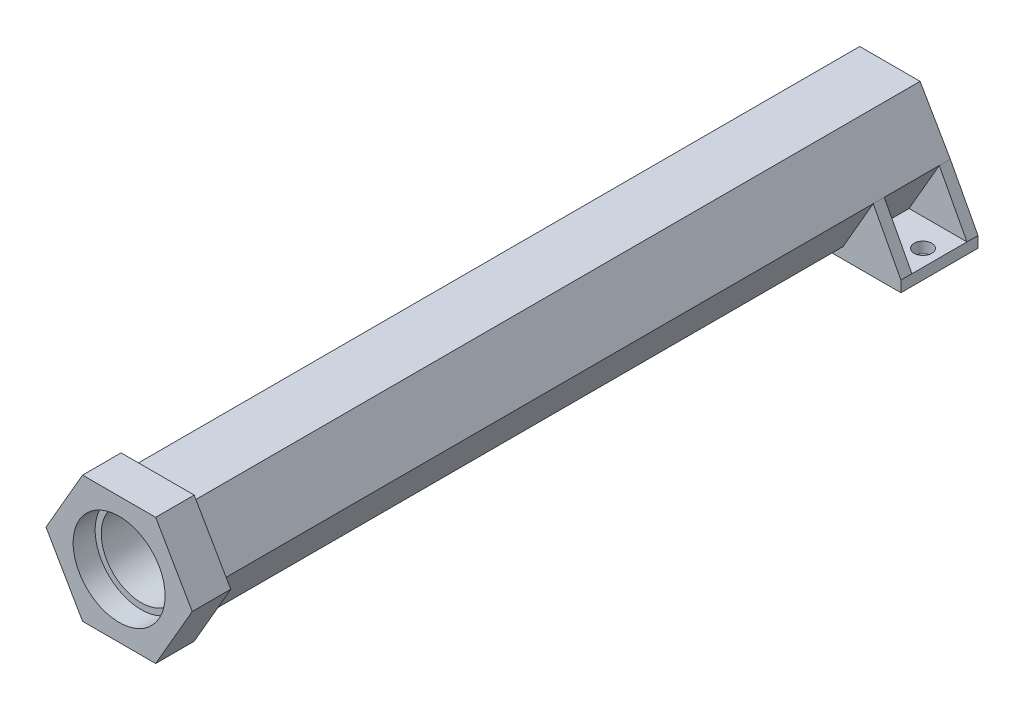
from build123d import *

# Parameters (mm, degrees)
SKIZZE1_R                        = 7.25
AUFSATZ_LINEAR_AUSTRAGEN1_DEPTH  = 136
SKIZZE2_R                        = 7.25
AUFSATZ_LINEAR_AUSTRAGEN2_DEPTH  = 2
SKIZZE3_R                        = 8.35
AUFSATZ_LINEAR_AUSTRAGEN3_DEPTH  = 7
AUFSATZ_LINEAR_AUSTRAGEN6_DEPTH  = 2
LINEARES_MUSTER3_COUNT           = 2
LINEARES_MUSTER3_PITCH           = 12
SKIZZE12_W                       = 32
SKIZZE12_H                       = 14
SKIZZE12_R                       = 1.6
AUFSATZ_LINEAR_AUSTRAGEN14_DEPTH = 2
SKIZZE14_R                       = 2.6
SCHNITT_LINEAR_AUSTRAGEN1_DEPTH  = 2


with BuildPart() as part:
    # Skizze1 → Aufsatz-Linear austragen1 (new body)
    with BuildSketch(Plane.XY):
        Polygon((-10.969655115, 0), (-5.484827557, -9.5), (5.484827557, -9.5), (10.969655115, 0), (5.484827557, 9.5), (-5.484827557, 9.5), align=None)
        Circle(SKIZZE1_R, mode=Mode.SUBTRACT)
    extrude(amount=AUFSATZ_LINEAR_AUSTRAGEN1_DEPTH)

    # Skizze2 → Aufsatz-Linear austragen2 (add)
    with BuildSketch(Plane.XY):
        Circle(SKIZZE2_R)
    extrude(amount=AUFSATZ_LINEAR_AUSTRAGEN2_DEPTH)

    # Skizze3 → Aufsatz-Linear austragen3 (add)
    with BuildSketch(Plane.XY.offset(133)):
        Polygon((13.279056191, 0), (6.639528096, 11.5), (-6.639528096, 11.5), (-13.279056191, 0), (-6.639528096, -11.5), (6.639528096, -11.5), align=None)
        Circle(SKIZZE3_R, mode=Mode.SUBTRACT)
    extrude(amount=AUFSATZ_LINEAR_AUSTRAGEN3_DEPTH)

    # Skizze7 → Aufsatz-Linear austragen6 (add)
    with BuildSketch(Plane.XY):
        Polygon((10.969655115, 0), (5.484827557, -9.5), (16, -9.5), align=None)
        Polygon((-5.484827557, -9.5), (-10.969655115, 0), (-16, -9.5), align=None)
    aufsatz_linear_austragen6 = extrude(amount=AUFSATZ_LINEAR_AUSTRAGEN6_DEPTH)

    # Lineares Muster3: Aufsatz-Linear austragen6 ×2
    with Locations(*[(0, 0, i * LINEARES_MUSTER3_PITCH) for i in range(1, LINEARES_MUSTER3_COUNT)]):
        add(aufsatz_linear_austragen6)

    # Skizze12 → Aufsatz-Linear austragen14 (add)
    with BuildSketch(Plane.XZ.offset(9.5)):
        with Locations((0, 7)):
            Rectangle(SKIZZE12_W, SKIZZE12_H)
        with Locations((-13, 7)):
            Circle(SKIZZE12_R, mode=Mode.SUBTRACT)
        with Locations((13, 7)):
            Circle(SKIZZE12_R, mode=Mode.SUBTRACT)
    extrude(amount=AUFSATZ_LINEAR_AUSTRAGEN14_DEPTH)

    # Skizze14 → Schnitt-Linear austragen1 (cut)
    with BuildSketch(Plane(origin=(0, 0, 0), x_dir=(-1, 0, 0), z_dir=(0, 0, -1))):
        Circle(SKIZZE14_R)
    extrude(amount=-SCHNITT_LINEAR_AUSTRAGEN1_DEPTH, mode=Mode.SUBTRACT)


solid = part.part
